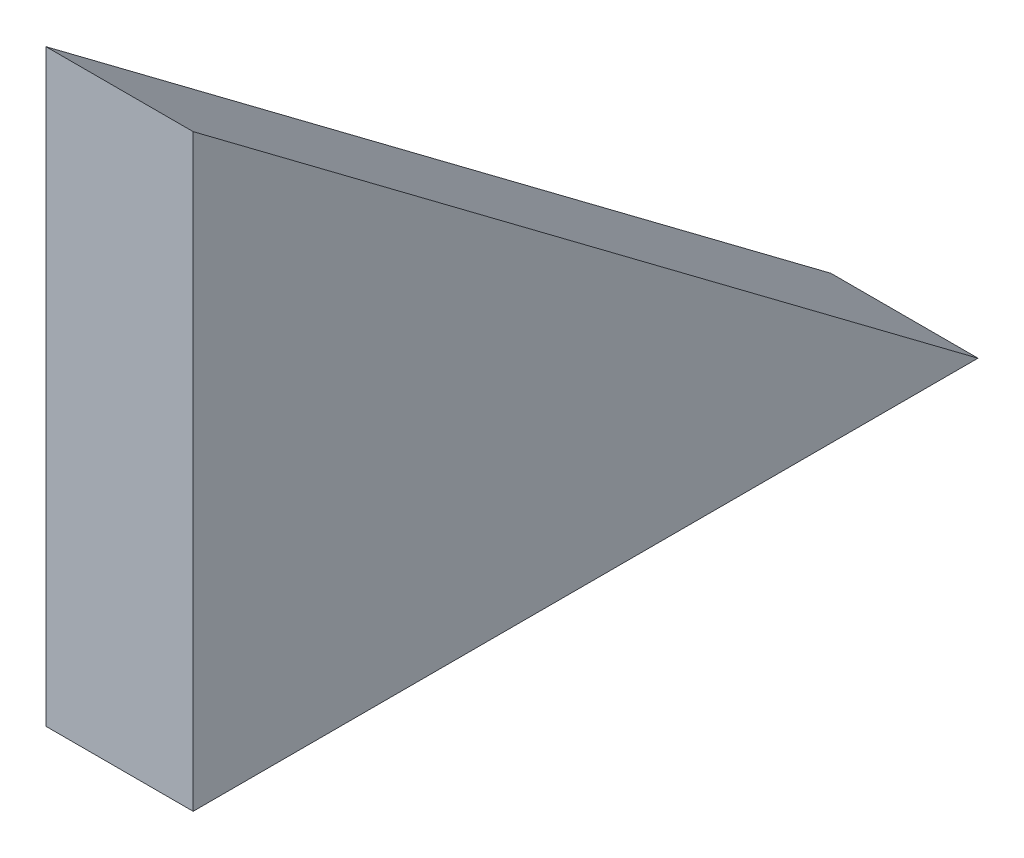
from build123d import *

# Parameters (mm, degrees)
BOSS_EXTRUDE1_DEPTH = 9.525


with BuildPart() as part:
    # Sketch1 → Boss-Extrude1 (new body, symmetric)
    with BuildSketch(Plane(origin=(0, 0, 0), x_dir=(0, 0, -1), z_dir=(1, 0, 0))):
        Polygon((0, 0), (0, 76.2), (101.6, 0), align=None)
    extrude(amount=BOSS_EXTRUDE1_DEPTH, both=True)


solid = part.part
